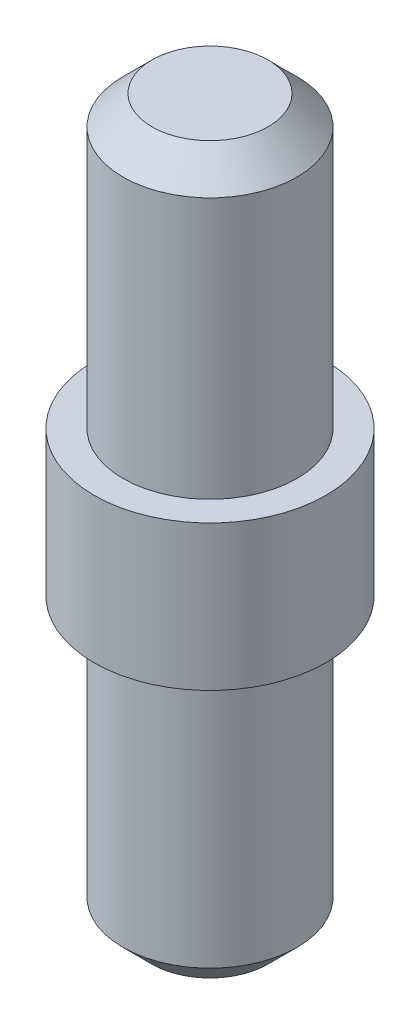
from build123d import *


with BuildPart() as part:
    # 草圖1 → 旋轉1 (revolve)
    with BuildSketch(Plane.XY):
        Polygon((2, 25), (3, 24), (3, 15), (4, 15), (4, 10), (3, 10), (3, 1), (2, 0), (0, 0), (0, 25), align=None)
    revolve(axis=Axis((0, 66.758331831, 0), (0, -1, 0)))


solid = part.part
